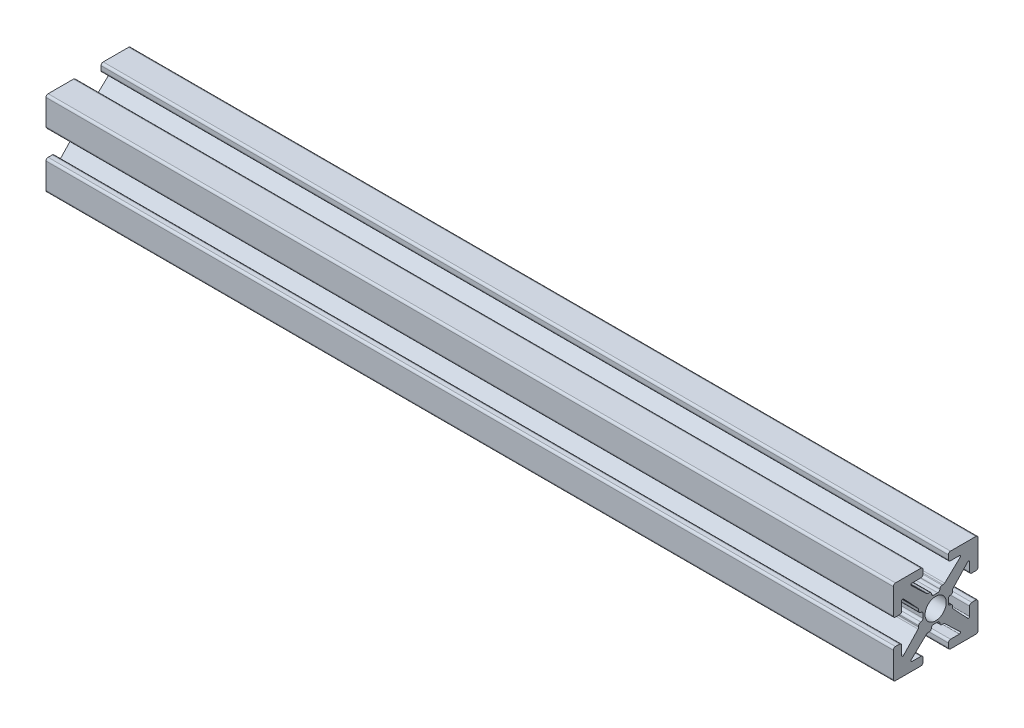
from build123d import *

# Parameters (mm, degrees)
ESTRUSIONE_ESTRUSIONE1_DEPTH = 100
FORO_FILETTATO_M3X0_5_1_D    = 2.5


with BuildPart() as part:
    # Sketch1 → Estrusione-Estrusione1 (new body)
    with BuildSketch(Plane(origin=(0, 0, 0), x_dir=(0, 0, -1), z_dir=(1, 0, 0))):
        with BuildLine():
            Line((-0.2413, 1.4948), (0.2413, 1.4948))
            ThreePointArc((0.2413, 1.4948), (0.420905122, 1.569194878), (0.4953, 1.7488))
            ThreePointArc((0.4953, 1.7488), (0.569694878, 1.928405122), (0.7493, 2.0028))
            Line((0.7493, 2.0028), (0.889923986, 2.0028))
            ThreePointArc((0.889923986, 2.0028), (0.983516259, 2.020671886), (1.063937899, 2.071772548))
            Line((1.063937899, 2.071772548), (2.890793, 3.789886274))
            ThreePointArc((2.890793, 3.789886274), (2.921850101, 3.929196137), (2.803786044, 4.0094))
            Line((2.803786044, 4.0094), (1.7526, 4.0094))
            ThreePointArc((1.7526, 4.0094), (1.572994878, 4.083794878), (1.4986, 4.2634))
            Line((1.4986, 4.2634), (1.4986, 4.746))
            ThreePointArc((1.4986, 4.746), (1.572994878, 4.925605122), (1.7526, 5))
            Line((1.7526, 5), (4.746, 5))
            ThreePointArc((4.746, 5), (4.925605122, 4.925605122), (5, 4.746))
            Line((5, 4.746), (5, 1.7526))
            ThreePointArc((5, 1.7526), (4.925605122, 1.572994878), (4.746, 1.4986))
            Line((4.746, 1.4986), (4.2634, 1.4986))
            ThreePointArc((4.2634, 1.4986), (4.083794878, 1.572994878), (4.0094, 1.7526))
            Line((4.0094, 1.7526), (4.0094, 2.803786044))
            ThreePointArc((4.0094, 2.803786044), (3.929196137, 2.921850101), (3.789886274, 2.890793))
            Line((3.789886274, 2.890793), (2.071772548, 1.063937899))
            ThreePointArc((2.071772548, 1.063937899), (2.020671886, 0.983516259), (2.0028, 0.889923986))
            Line((2.0028, 0.889923986), (2.0028, 0.7493))
            ThreePointArc((2.0028, 0.7493), (1.928405122, 0.569694878), (1.7488, 0.4953))
            ThreePointArc((1.7488, 0.4953), (1.569194878, 0.420905122), (1.4948, 0.2413))
            Line((1.4948, 0.2413), (1.4948, -0.2413))
            ThreePointArc((1.4948, -0.2413), (1.569194878, -0.420905122), (1.7488, -0.4953))
            ThreePointArc((1.7488, -0.4953), (1.928405122, -0.569694878), (2.0028, -0.7493))
            Line((2.0028, -0.7493), (2.0028, -0.889923986))
            ThreePointArc((2.0028, -0.889923986), (2.020671886, -0.983516259), (2.071772548, -1.063937899))
            Line((2.071772548, -1.063937899), (3.789886274, -2.890793))
            ThreePointArc((3.789886274, -2.890793), (3.929196137, -2.921850101), (4.0094, -2.803786044))
            Line((4.0094, -2.803786044), (4.0094, -1.7526))
            ThreePointArc((4.0094, -1.7526), (4.083794878, -1.572994878), (4.2634, -1.4986))
            Line((4.2634, -1.4986), (4.746, -1.4986))
            ThreePointArc((4.746, -1.4986), (4.925605122, -1.572994878), (5, -1.7526))
            Line((5, -1.7526), (5, -4.746))
            ThreePointArc((5, -4.746), (4.925605122, -4.925605122), (4.746, -5))
            Line((4.746, -5), (1.7526, -5))
            ThreePointArc((1.7526, -5), (1.572994878, -4.925605122), (1.4986, -4.746))
            Line((1.4986, -4.746), (1.4986, -4.2634))
            ThreePointArc((1.4986, -4.2634), (1.572994878, -4.083794878), (1.7526, -4.0094))
            Line((1.7526, -4.0094), (2.803786044, -4.0094))
            ThreePointArc((2.803786044, -4.0094), (2.921850101, -3.929196137), (2.890793, -3.789886274))
            Line((2.890793, -3.789886274), (1.063937899, -2.071772548))
            ThreePointArc((1.063937899, -2.071772548), (0.983516259, -2.020671886), (0.889923986, -2.0028))
            Line((0.889923986, -2.0028), (0.7493, -2.0028))
            ThreePointArc((0.7493, -2.0028), (0.569694878, -1.928405122), (0.4953, -1.7488))
            ThreePointArc((0.4953, -1.7488), (0.420905122, -1.569194878), (0.2413, -1.4948))
            Line((0.2413, -1.4948), (-0.2413, -1.4948))
            ThreePointArc((-0.2413, -1.4948), (-0.420905122, -1.569194878), (-0.4953, -1.7488))
            ThreePointArc((-0.4953, -1.7488), (-0.569694878, -1.928405122), (-0.7493, -2.0028))
            Line((-0.7493, -2.0028), (-0.889923986, -2.0028))
            ThreePointArc((-0.889923986, -2.0028), (-0.983516259, -2.020671886), (-1.063937899, -2.071772548))
            Line((-1.063937899, -2.071772548), (-2.890793, -3.789886274))
            ThreePointArc((-2.890793, -3.789886274), (-2.921850101, -3.929196137), (-2.803786044, -4.0094))
            Line((-2.803786044, -4.0094), (-1.7526, -4.0094))
            ThreePointArc((-1.7526, -4.0094), (-1.572994878, -4.083794878), (-1.4986, -4.2634))
            Line((-1.4986, -4.2634), (-1.4986, -4.746))
            ThreePointArc((-1.4986, -4.746), (-1.572994878, -4.925605122), (-1.7526, -5))
            Line((-1.7526, -5), (-4.746, -5))
            ThreePointArc((-4.746, -5), (-4.925605122, -4.925605122), (-5, -4.746))
            Line((-5, -4.746), (-5, -1.7526))
            ThreePointArc((-5, -1.7526), (-4.925605122, -1.572994878), (-4.746, -1.4986))
            Line((-4.746, -1.4986), (-4.2634, -1.4986))
            ThreePointArc((-4.2634, -1.4986), (-4.083794878, -1.572994878), (-4.0094, -1.7526))
            Line((-4.0094, -1.7526), (-4.0094, -2.803786044))
            ThreePointArc((-4.0094, -2.803786044), (-3.929196137, -2.921850101), (-3.789886274, -2.890793))
            Line((-3.789886274, -2.890793), (-2.071772548, -1.063937899))
            ThreePointArc((-2.071772548, -1.063937899), (-2.020671886, -0.983516259), (-2.0028, -0.889923986))
            Line((-2.0028, -0.889923986), (-2.0028, -0.7493))
            ThreePointArc((-2.0028, -0.7493), (-1.928405122, -0.569694878), (-1.7488, -0.4953))
            ThreePointArc((-1.7488, -0.4953), (-1.569194878, -0.420905122), (-1.4948, -0.2413))
            Line((-1.4948, -0.2413), (-1.4948, 0.2413))
            ThreePointArc((-1.4948, 0.2413), (-1.569194878, 0.420905122), (-1.7488, 0.4953))
            ThreePointArc((-1.7488, 0.4953), (-1.928405122, 0.569694878), (-2.0028, 0.7493))
            Line((-2.0028, 0.7493), (-2.0028, 0.889923986))
            ThreePointArc((-2.0028, 0.889923986), (-2.020671886, 0.983516259), (-2.071772548, 1.063937899))
            Line((-2.071772548, 1.063937899), (-3.789886274, 2.890793))
            ThreePointArc((-3.789886274, 2.890793), (-3.929196137, 2.921850101), (-4.0094, 2.803786044))
            Line((-4.0094, 2.803786044), (-4.0094, 1.7526))
            ThreePointArc((-4.0094, 1.7526), (-4.083794878, 1.572994878), (-4.2634, 1.4986))
            Line((-4.2634, 1.4986), (-4.746, 1.4986))
            ThreePointArc((-4.746, 1.4986), (-4.925605122, 1.572994878), (-5, 1.7526))
            Line((-5, 1.7526), (-5, 4.746))
            ThreePointArc((-5, 4.746), (-4.925605122, 4.925605122), (-4.746, 5))
            Line((-4.746, 5), (-1.7526, 5))
            ThreePointArc((-1.7526, 5), (-1.572994878, 4.925605122), (-1.4986, 4.746))
            Line((-1.4986, 4.746), (-1.4986, 4.2634))
            ThreePointArc((-1.4986, 4.2634), (-1.572994878, 4.083794878), (-1.7526, 4.0094))
            Line((-1.7526, 4.0094), (-2.803786044, 4.0094))
            ThreePointArc((-2.803786044, 4.0094), (-2.921850101, 3.929196137), (-2.890793, 3.789886274))
            Line((-2.890793, 3.789886274), (-1.063937899, 2.071772548))
            ThreePointArc((-1.063937899, 2.071772548), (-0.983516259, 2.020671886), (-0.889923986, 2.0028))
            Line((-0.889923986, 2.0028), (-0.7493, 2.0028))
            ThreePointArc((-0.7493, 2.0028), (-0.569694878, 1.928405122), (-0.4953, 1.7488))
            ThreePointArc((-0.4953, 1.7488), (-0.420905122, 1.569194878), (-0.2413, 1.4948))
        make_face()
    extrude(amount=ESTRUSIONE_ESTRUSIONE1_DEPTH)

    # Foro filettato M3x0.5-1 (through all)
    with Locations(Plane.ZY):
        with Locations((0, 0)):
            Hole(FORO_FILETTATO_M3X0_5_1_D / 2)


solid = part.part
